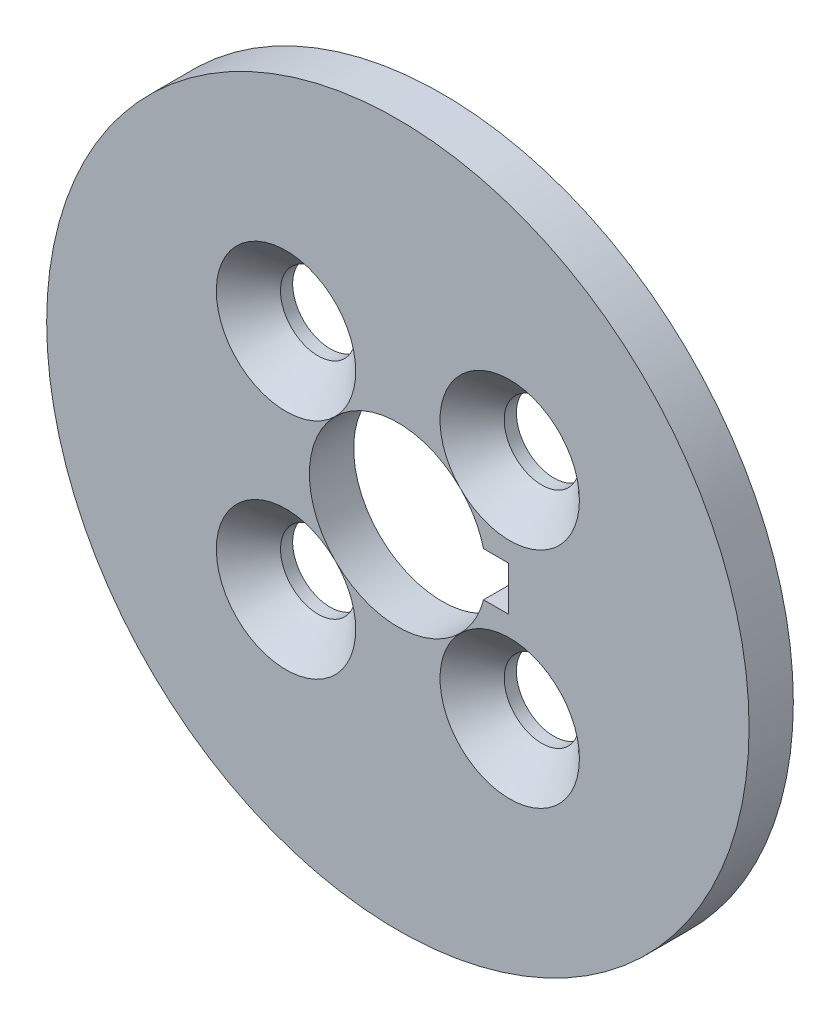
from build123d import *

# Parameters (mm, degrees)
SKETCH2_R                                      = 15.875
SKETCH2_R_2                                    = 1.7
SKETCH2_R_3                                    = 4
BOSS_EXTRUDE1_DEPTH                            = 2
CSK_FOR_M3_FLAT_HEAD_MACHINE_SCREW2_AT_2_COUNT = 2
CSK_FOR_M3_FLAT_HEAD_MACHINE_SCREW2_AT_2_PITCH = 10.111626971
CSK_FOR_M3_FLAT_HEAD_MACHINE_SCREW2_AT_3_COUNT = 2
CSK_FOR_M3_FLAT_HEAD_MACHINE_SCREW2_AT_3_PITCH = 14.3
CSK_FOR_M3_FLAT_HEAD_MACHINE_SCREW2_AT_4_COUNT = 2
CSK_FOR_M3_FLAT_HEAD_MACHINE_SCREW2_AT_4_PITCH = 10.111626971
SKETCH5_W                                      = 1.314472485
SKETCH5_H                                      = 2
CUT_EXTRUDE1_DEPTH                             = 3


with BuildPart() as part:
    # Sketch2 → Boss-Extrude1 (new body)
    with BuildSketch(Plane.XY):
        with Locations((-160.606756626, 98.885631483)):
            Circle(SKETCH2_R)
        with Locations((-165.662570112, 103.941444968)):
            Circle(SKETCH2_R_2, mode=Mode.SUBTRACT)
        with Locations((-155.550943141, 103.941444968)):
            Circle(SKETCH2_R_2, mode=Mode.SUBTRACT)
        with Locations((-155.550943141, 93.829817997)):
            Circle(SKETCH2_R_2, mode=Mode.SUBTRACT)
        with Locations((-165.662570112, 93.829817997)):
            Circle(SKETCH2_R_2, mode=Mode.SUBTRACT)
        with Locations((-160.606756626, 98.885631483)):
            Circle(SKETCH2_R_3, mode=Mode.SUBTRACT)
    extrude(amount=BOSS_EXTRUDE1_DEPTH)

    # Sketch4 → CSK for M3 Flat Head Machine Screw2 (revolve, cut)
    with BuildSketch(Plane(origin=(-165.662570112, 103.941444968, 2), x_dir=(0, -1, 0), z_dir=(1, 0, 0))):
        Polygon((0, 0), (0, 2), (1.7, 2), (1.7, 1.45), (3.15, 0), align=None)
    csk_for_m3_flat_head_machine_screw2 = revolve(axis=Axis((-165.662570112, 103.941444968, 8.35), (0, 0, -1)), mode=Mode.SUBTRACT)

    # CSK for M3 Flat Head Machine Screw2 at 2: CSK for M3 Flat Head Machine Screw2 ×2
    with Locations(*[(i * CSK_FOR_M3_FLAT_HEAD_MACHINE_SCREW2_AT_2_PITCH, 0, 0) for i in range(1, CSK_FOR_M3_FLAT_HEAD_MACHINE_SCREW2_AT_2_COUNT)]):
        add(csk_for_m3_flat_head_machine_screw2, mode=Mode.SUBTRACT)

    # CSK for M3 Flat Head Machine Screw2 at 3: CSK for M3 Flat Head Machine Screw2 ×2
    with Locations(*[Vector(0.707106781, -0.707106781, 0) * (i * CSK_FOR_M3_FLAT_HEAD_MACHINE_SCREW2_AT_3_PITCH) for i in range(1, CSK_FOR_M3_FLAT_HEAD_MACHINE_SCREW2_AT_3_COUNT)]):
        add(csk_for_m3_flat_head_machine_screw2, mode=Mode.SUBTRACT)

    # CSK for M3 Flat Head Machine Screw2 at 4: CSK for M3 Flat Head Machine Screw2 ×2
    with Locations(*[(0, -i * CSK_FOR_M3_FLAT_HEAD_MACHINE_SCREW2_AT_4_PITCH, 0) for i in range(1, CSK_FOR_M3_FLAT_HEAD_MACHINE_SCREW2_AT_4_COUNT)]):
        add(csk_for_m3_flat_head_machine_screw2, mode=Mode.SUBTRACT)

    # Sketch5 → Cut-Extrude1 (cut, through all)
    with BuildSketch(Plane(origin=(0, 0, 0), x_dir=(-1, 0, 0), z_dir=(0, 0, -1))):
        with Locations((156.263992868, 98.885631483)):
            Rectangle(SKETCH5_W, SKETCH5_H)
    extrude(amount=-CUT_EXTRUDE1_DEPTH, mode=Mode.SUBTRACT)


solid = part.part
